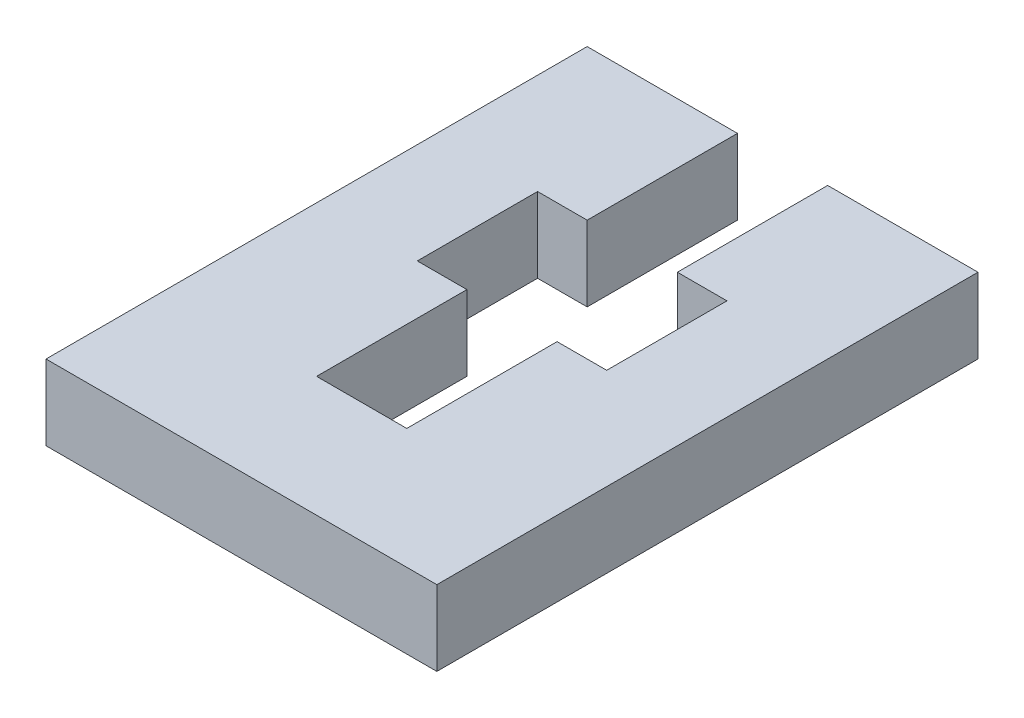
from build123d import *

# Parameters (mm, degrees)
BOSS_EXTRUDE1_DEPTH = 2.5


with BuildPart() as part:
    # Sketch1 → Boss-Extrude1 (new body)
    with BuildSketch(Plane(origin=(0, 0, 0), x_dir=(1, 0, 0), z_dir=(0, 1, 0))):
        Polygon((1.5, 8.5), (1.5, 3.5), (3.15, 3.5), (3.15, -0.5), (1.5, -0.5), (1.5, -5.5), (-1.5, -5.5), (-1.5, -0.5), (-3.15, -0.5), (-3.15, 3.5), (-1.5, 3.5), (-1.5, 8.5), (-6.5, 8.5), (-6.5, -9.5), (6.5, -9.5), (6.5, 8.5), align=None)
    extrude(amount=BOSS_EXTRUDE1_DEPTH)


solid = part.part
